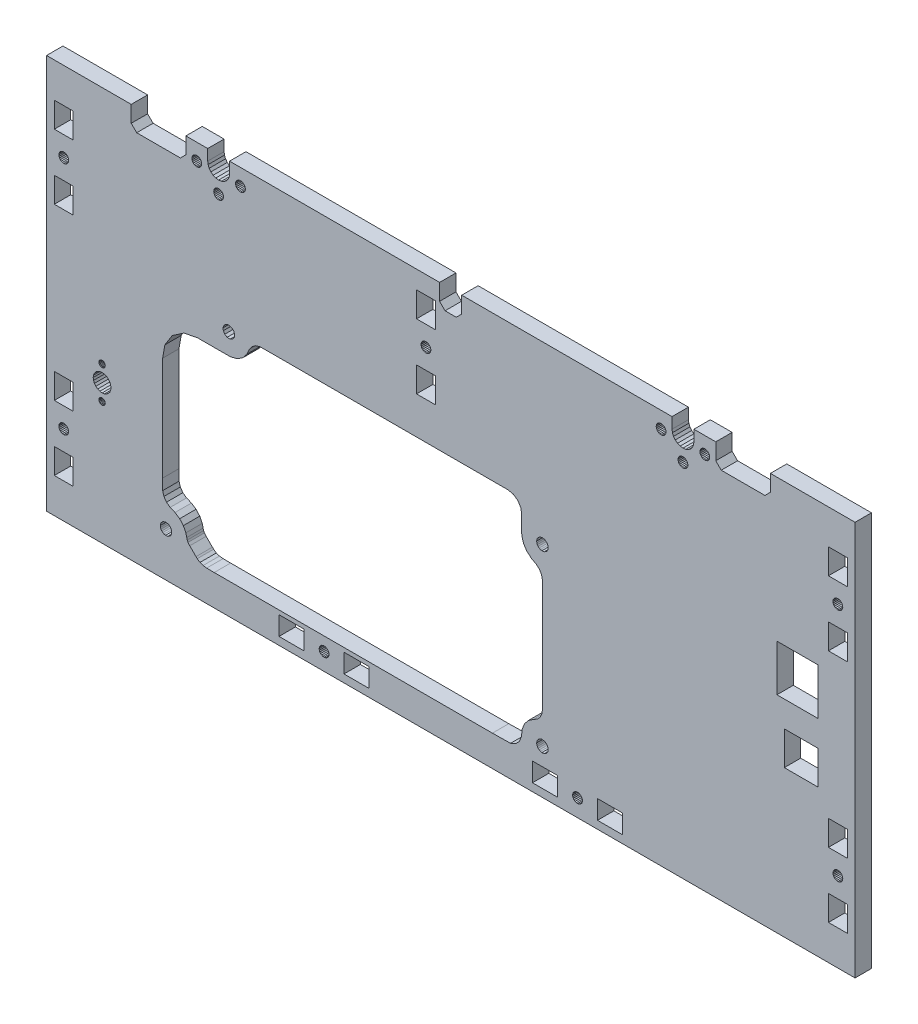
from build123d import *

# Parameters (mm, degrees)
SKETCH1_W           = 9.199995837
SKETCH1_H           = 6.900001918
SKETCH1_W_2         = 9.1999977
SKETCH1_W_3         = 6.900001918
SKETCH1_H_2         = 9.1999977
SKETCH1_H_3         = 9.199995837
SKETCH1_W_4         = 6.900001917
SKETCH1_W_5         = 15
SKETCH1_H_4         = 17
SKETCH1_W_6         = 12.3
SKETCH1_H_5         = 12.3
BOSS_EXTRUDE1_DEPTH = 6


with BuildPart() as part:
    # Sketch1 → Boss-Extrude1 (new body)
    with BuildSketch(Plane.XY):
        Polygon((-23.944821085, -85.732154182), (-22.980097574, -86.131755744), (-21.944821725, -86.268052395), (-20.909545876, -86.131755744), (-19.944822365, -85.732154182), (-19.116395506, -85.096479895), (-18.480721219, -84.268053035), (-18.081119656, -83.303329524), (-17.944823005, -82.268053675), (-17.944823005, -78.268054955), (-9.944825565, -78.268054955), (-9.944825565, -84.268053035), (-7.944826205, -86.268052395), (8.055168675, -86.268052395), (10.055168035, -84.268053035), (10.055168035, -78.268054955), (41.055158115, -78.268054955), (41.055158115, -222.768036235), (-254.944747165, -222.768036235), (-254.944747165, -78.268054955), (-223.944757085, -78.268054955), (-223.944757085, -84.268053035), (-221.944757725, -86.268052395), (-205.944762845, -86.268052395), (-203.944763485, -84.268053035), (-203.944763485, -78.268054955), (-195.944766045, -78.268054955), (-195.944766045, -82.268053675), (-195.808469394, -83.303329524), (-195.408867832, -84.268053035), (-194.773193545, -85.096479895), (-193.944766685, -85.732154182), (-192.980043174, -86.131755744), (-191.944767325, -86.268052395), (-190.909491476, -86.131755744), (-189.944767965, -85.732154182), (-189.116341106, -85.096479895), (-188.480666819, -84.268053035), (-188.081065256, -83.303329524), (-187.944768605, -82.268053675), (-187.944768605, -78.268054955), (-111.044791325, -78.268054955), (-111.044791325, -84.268053035), (-109.044791965, -86.268052395), (-104.944797085, -86.268052395), (-102.944797725, -84.268053035), (-102.944797725, -78.268054955), (-25.944820445, -78.268054955), (-25.944820445, -82.268053675), (-25.808523794, -83.303329524), (-25.408922232, -84.268053035), (-24.773247945, -85.096479895), align=None)
        Polygon((-201.503609993, -85.168052747), (-201.217556564, -85.540844834), (-200.844764477, -85.826898263), (-200.410638897, -86.006718966), (-199.944764765, -86.068052459), (-199.478890633, -86.006718966), (-199.044765053, -85.826898263), (-198.671972966, -85.540844834), (-198.385919537, -85.168052747), (-198.206098834, -84.733927167), (-198.144765341, -84.268053035), (-198.206098834, -83.802178903), (-198.385919537, -83.368053323), (-198.671972966, -82.995261236), (-199.044765053, -82.709207807), (-199.478890633, -82.529387104), (-199.944764765, -82.468053611), (-200.410638897, -82.529387104), (-200.844764477, -82.709207807), (-201.217556564, -82.995261236), (-201.503609993, -83.368053323), (-201.683430696, -83.802178903), (-201.744764189, -84.268053035), (-201.683430696, -84.733927167), align=None, mode=Mode.SUBTRACT)
        Polygon((35.221479877, -105.677712709), (34.755159077, -105.616320411), (34.288838277, -105.677712709), (33.854296469, -105.85770582), (33.481146959, -106.144033509), (33.19481927, -106.517183019), (33.014826159, -106.951724827), (32.953433861, -107.418045627), (33.014826159, -107.884366427), (33.19481927, -108.318908235), (33.481146959, -108.692057745), (33.854296469, -108.978385434), (34.288838277, -109.158378545), (34.755159077, -109.219770843), (35.221479877, -109.158378545), (35.656021685, -108.978385434), (36.029171195, -108.692057745), (36.315498884, -108.318908235), (36.495491995, -107.884366427), (36.556884293, -107.418045627), (36.495491995, -106.951724827), (36.315498884, -106.517183019), (36.029171195, -106.144033509), (35.656021685, -105.85770582), align=None, mode=Mode.SUBTRACT)
        Polygon((-185.504731524, -85.168052747), (-185.218678095, -85.540844834), (-184.845886008, -85.826898263), (-184.411760428, -86.006718966), (-183.945886296, -86.068052459), (-183.480012164, -86.006718966), (-183.045886584, -85.826898263), (-182.673094497, -85.540844834), (-182.387041068, -85.168052747), (-182.207220365, -84.733927167), (-182.145886872, -84.268053035), (-182.207220365, -83.802178903), (-182.387041068, -83.368053323), (-182.673094497, -82.995261236), (-183.045886584, -82.709207807), (-183.480012164, -82.529387104), (-183.945886296, -82.468053611), (-184.411760428, -82.529387104), (-184.845886008, -82.709207807), (-185.218678095, -82.995261236), (-185.504731524, -83.368053323), (-185.684552227, -83.802178903), (-185.74588572, -84.268053035), (-185.684552227, -84.733927167), align=None, mode=Mode.SUBTRACT)
        Polygon((-21.044822013, -92.326896183), (-20.672029926, -92.040842754), (-20.385976497, -91.668050667), (-20.206155794, -91.233925087), (-20.144822301, -90.768050955), (-20.206155794, -90.302176823), (-20.385976497, -89.868051243), (-20.672029926, -89.495259156), (-21.044822013, -89.209205727), (-21.478947593, -89.029385024), (-21.944821725, -88.968051531), (-22.410695857, -89.029385024), (-22.844821437, -89.209205727), (-23.217613524, -89.495259156), (-23.503666953, -89.868051243), (-23.683487656, -90.302176823), (-23.744821149, -90.768050955), (-23.683487656, -91.233925087), (-23.503666953, -91.668050667), (-23.217613524, -92.040842754), (-22.844821437, -92.326896183), (-22.410695857, -92.506716886), (-21.944821725, -92.568050379), (-21.478947593, -92.506716886), align=None, mode=Mode.SUBTRACT)
        Polygon((-15.684606627, -83.802178903), (-15.74594012, -84.268053035), (-15.684606627, -84.733927167), (-15.504785924, -85.168052747), (-15.218732495, -85.540844834), (-14.845940408, -85.826898263), (-14.411814828, -86.006718966), (-13.945940696, -86.068052459), (-13.480066564, -86.006718966), (-13.045940984, -85.826898263), (-12.673148897, -85.540844834), (-12.387095468, -85.168052747), (-12.207274765, -84.733927167), (-12.145941272, -84.268053035), (-12.207274765, -83.802178903), (-12.387095468, -83.368053323), (-12.673148897, -82.995261236), (-13.045940984, -82.709207807), (-13.480066564, -82.529387104), (-13.945940696, -82.468053611), (-14.411814828, -82.529387104), (-14.845940408, -82.709207807), (-15.218732495, -82.995261236), (-15.504785924, -83.368053323), align=None, mode=Mode.SUBTRACT)
        Polygon((-250.205086013, -108.418908203), (-249.918758324, -108.792057713), (-249.545608814, -109.078385402), (-249.111067006, -109.258378513), (-248.644746206, -109.319770811), (-248.178425406, -109.258378513), (-247.743883598, -109.078385402), (-247.370734088, -108.792057713), (-247.084406398, -108.418908203), (-246.904413288, -107.984366395), (-246.84302099, -107.518045595), (-246.904413288, -107.051724795), (-247.084406398, -106.617182987), (-247.370734088, -106.244033477), (-247.743883598, -105.957705788), (-248.178425406, -105.777712677), (-248.644746206, -105.716320379), (-249.111067006, -105.777712677), (-249.545608814, -105.957705788), (-249.918758324, -106.244033477), (-250.205086013, -106.617182987), (-250.385079123, -107.051724795), (-250.446471421, -107.518045595), (-250.385079123, -107.984366395), align=None, mode=Mode.SUBTRACT)
        Polygon((-192.844767037, -92.326896183), (-192.410641457, -92.506716886), (-191.944767325, -92.568050379), (-191.478893193, -92.506716886), (-191.044767613, -92.326896183), (-190.671975526, -92.040842754), (-190.385922097, -91.668050667), (-190.206101394, -91.233925087), (-190.144767901, -90.768050955), (-190.206101394, -90.302176823), (-190.385922097, -89.868051243), (-190.671975526, -89.495259156), (-191.044767613, -89.209205727), (-191.478893193, -89.029385024), (-191.944767325, -88.968051531), (-192.410641457, -89.029385024), (-192.844767037, -89.209205727), (-193.217559124, -89.495259156), (-193.503612553, -89.868051243), (-193.683433256, -90.302176823), (-193.744766749, -90.768050955), (-193.683433256, -91.233925087), (-193.503612553, -91.668050667), (-193.217559124, -92.040842754), align=None, mode=Mode.SUBTRACT)
        Polygon((-60.544813403, -218.269763467), (-60.078492603, -218.208371169), (-59.643950795, -218.028378058), (-59.270801285, -217.742050369), (-58.984473595, -217.368900859), (-58.804480485, -216.934359051), (-58.743088187, -216.468038251), (-58.804480485, -216.001717451), (-58.984473595, -215.567175643), (-59.270801285, -215.194026133), (-59.643950795, -214.907698444), (-60.078492603, -214.727705333), (-60.544813403, -214.666313035), (-61.011134202, -214.727705333), (-61.44567601, -214.907698444), (-61.81882552, -215.194026133), (-62.10515321, -215.567175643), (-62.28514632, -216.001717451), (-62.346538618, -216.468038251), (-62.28514632, -216.934359051), (-62.10515321, -217.368900859), (-61.81882552, -217.742050369), (-61.44567601, -218.028378058), (-61.011134202, -218.208371169), align=None, mode=Mode.SUBTRACT)
        Polygon((-153.811096448, -214.727705333), (-154.245638256, -214.907698444), (-154.618787766, -215.194026133), (-154.905115455, -215.567175643), (-155.085108566, -216.001717451), (-155.146500864, -216.468038251), (-155.085108566, -216.934359051), (-154.905115455, -217.368900859), (-154.618787766, -217.742050369), (-154.245638256, -218.028378058), (-153.811096448, -218.208371169), (-153.344775648, -218.269763467), (-152.878454848, -218.208371169), (-152.44391304, -218.028378058), (-152.07076353, -217.742050369), (-151.784435841, -217.368900859), (-151.60444273, -216.934359051), (-151.543050432, -216.468038251), (-151.60444273, -216.001717451), (-151.784435841, -215.567175643), (-152.07076353, -215.194026133), (-152.44391304, -214.907698444), (-152.878454848, -214.727705333), (-153.344775648, -214.666313035), align=None, mode=Mode.SUBTRACT)
        Polygon((-29.044819453, -82.709207807), (-29.478945033, -82.529387104), (-29.944819165, -82.468053611), (-30.410693297, -82.529387104), (-30.844818877, -82.709207807), (-31.217610964, -82.995261236), (-31.503664393, -83.368053323), (-31.683485096, -83.802178903), (-31.744818589, -84.268053035), (-31.683485096, -84.733927167), (-31.503664393, -85.168052747), (-31.217610964, -85.540844834), (-30.844818877, -85.826898263), (-30.410693297, -86.006718966), (-29.944819165, -86.068052459), (-29.478945033, -86.006718966), (-29.044819453, -85.826898263), (-28.672027366, -85.540844834), (-28.385973937, -85.168052747), (-28.206153234, -84.733927167), (-28.144819741, -84.268053035), (-28.206153234, -83.802178903), (-28.385973937, -83.368053323), (-28.672027366, -82.995261236), align=None, mode=Mode.SUBTRACT)
        with Locations((-48.644817352, -216.46803729)):
            Rectangle(SKETCH1_W, SKETCH1_H, mode=Mode.SUBTRACT)
        with Locations((-72.444808182, -216.46803729)):
            Rectangle(SKETCH1_W_2, SKETCH1_H, mode=Mode.SUBTRACT)
        with Locations((-165.244770427, -216.46803729)):
            Rectangle(SKETCH1_W_2, SKETCH1_H, mode=Mode.SUBTRACT)
        with Locations((-141.444779598, -216.46803729)):
            Rectangle(SKETCH1_W, SKETCH1_H, mode=Mode.SUBTRACT)
        with Locations((34.755158116, -119.318040406)):
            Rectangle(SKETCH1_W_3, SKETCH1_H_2, mode=Mode.SUBTRACT)
        with Locations((34.755158116, -95.518049577)):
            Rectangle(SKETCH1_W_3, SKETCH1_H_3, mode=Mode.SUBTRACT)
        with Locations((-248.644747167, -119.418040374)):
            Rectangle(SKETCH1_W_4, SKETCH1_H_2, mode=Mode.SUBTRACT)
        with Locations((-248.644747167, -95.618049544)):
            Rectangle(SKETCH1_W_4, SKETCH1_H_3, mode=Mode.SUBTRACT)
        with Locations((-248.644747167, -205.418037385)):
            Rectangle(SKETCH1_W_4, SKETCH1_H_2, mode=Mode.SUBTRACT)
        with Locations((-248.644747167, -181.618046556)):
            Rectangle(SKETCH1_W_4, SKETCH1_H_3, mode=Mode.SUBTRACT)
        Polygon((-246.904413288, -193.984363406), (-246.84302099, -193.518042606), (-246.904413288, -193.051721806), (-247.084406398, -192.617179998), (-247.370734088, -192.244030488), (-247.743883598, -191.957702798), (-248.178425406, -191.777709688), (-248.644746206, -191.71631739), (-249.111067006, -191.777709688), (-249.545608814, -191.957702798), (-249.918758324, -192.244030488), (-250.205086013, -192.617179998), (-250.385079123, -193.051721806), (-250.446471421, -193.518042606), (-250.385079123, -193.984363406), (-250.205086013, -194.418905214), (-249.918758324, -194.792054724), (-249.545608814, -195.078382413), (-249.111067006, -195.258375523), (-248.644746206, -195.319767821), (-248.178425406, -195.258375523), (-247.743883598, -195.078382413), (-247.370734088, -194.792054724), (-247.084406398, -194.418905214), align=None, mode=Mode.SUBTRACT)
        with Locations((34.755158116, -205.418037385)):
            Rectangle(SKETCH1_W_3, SKETCH1_H_2, mode=Mode.SUBTRACT)
        Polygon((36.495491995, -193.984363406), (36.556884293, -193.518042606), (36.495491995, -193.051721806), (36.315498884, -192.617179998), (36.029171195, -192.244030488), (35.656021685, -191.957702798), (35.221479877, -191.777709688), (34.755159077, -191.71631739), (34.288838277, -191.777709688), (33.854296469, -191.957702798), (33.481146959, -192.244030488), (33.19481927, -192.617179998), (33.014826159, -193.051721806), (32.953433861, -193.518042606), (33.014826159, -193.984363406), (33.19481927, -194.418905214), (33.481146959, -194.792054724), (33.854296469, -195.078382413), (34.288838277, -195.258375523), (34.755159077, -195.319767821), (35.221479877, -195.258375523), (35.656021685, -195.078382413), (36.029171195, -194.792054724), (36.315498884, -194.418905214), align=None, mode=Mode.SUBTRACT)
        with Locations((34.755158116, -181.618046556)):
            Rectangle(SKETCH1_W_3, SKETCH1_H_3, mode=Mode.SUBTRACT)
        Polygon((-232.993947452, -174.669693627), (-232.320850413, -174.153208103), (-231.80436489, -173.480111064), (-231.479688517, -172.696272961), (-231.368947452, -171.855111064), (-231.479688517, -171.013949168), (-231.80436489, -170.230111064), (-232.320850413, -169.557014025), (-232.993947452, -169.040528502), (-233.777785556, -168.715852129), (-234.618947452, -168.605111064), (-235.460109349, -168.715852129), (-236.243947452, -169.040528502), (-236.917044491, -169.557014025), (-237.433530015, -170.230111064), (-237.758206388, -171.013949168), (-237.868947452, -171.855111064), (-237.758206388, -172.696272961), (-237.433530015, -173.480111064), (-236.917044491, -174.153208103), (-236.243947452, -174.669693627), (-235.460109349, -174.99437), (-234.618947452, -175.105111064), (-233.777785556, -174.99437), align=None, mode=Mode.SUBTRACT)
        Polygon((-235.753910298, -166.190223442), (-235.636527302, -166.473611064), (-235.44979792, -166.716961532), (-235.206447452, -166.903690914), (-234.92305983, -167.02107391), (-234.618947452, -167.061111064), (-234.314835074, -167.02107391), (-234.031447452, -166.903690914), (-233.788096984, -166.716961532), (-233.601367603, -166.473611064), (-233.483984606, -166.190223442), (-233.443947452, -165.886111064), (-233.483984606, -165.581998686), (-233.601367603, -165.298611064), (-233.788096984, -165.055260596), (-234.031447452, -164.868531215), (-234.314835074, -164.751148218), (-234.618947452, -164.711111064), (-234.92305983, -164.751148218), (-235.206447452, -164.868531215), (-235.44979792, -165.055260596), (-235.636527302, -165.298611064), (-235.753910298, -165.581998686), (-235.793947452, -165.886111064), align=None, mode=Mode.SUBTRACT)
        Polygon((-234.314835074, -178.95907391), (-234.031447452, -178.841690914), (-233.788096984, -178.654961532), (-233.601367603, -178.411611064), (-233.483984606, -178.128223442), (-233.443947452, -177.824111064), (-233.483984606, -177.519998686), (-233.601367603, -177.236611064), (-233.788096984, -176.993260596), (-234.031447452, -176.806531215), (-234.314835074, -176.689148218), (-234.618947452, -176.649111064), (-234.92305983, -176.689148218), (-235.206447452, -176.806531215), (-235.44979792, -176.993260596), (-235.636527302, -177.236611064), (-235.753910298, -177.519998686), (-235.793947452, -177.824111064), (-235.753910298, -178.128223442), (-235.636527302, -178.411611064), (-235.44979792, -178.654961532), (-235.206447452, -178.841690914), (-234.92305983, -178.95907391), (-234.618947452, -178.999111064), align=None, mode=Mode.SUBTRACT)
        Polygon((-114.304458664, -100.880798627), (-114.484451774, -100.446256819), (-114.770779463, -100.073107309), (-115.143928973, -99.78677962), (-115.578470781, -99.60678651), (-116.044791581, -99.545394212), (-116.511112381, -99.60678651), (-116.945654189, -99.78677962), (-117.318803699, -100.073107309), (-117.605131389, -100.446256819), (-117.785124499, -100.880798627), (-117.846516797, -101.347119427), (-117.785124499, -101.813440227), (-117.605131389, -102.247982035), (-117.318803699, -102.621131545), (-116.945654189, -102.907459234), (-116.511112381, -103.087452345), (-116.044791581, -103.148844643), (-115.578470781, -103.087452345), (-115.143928973, -102.907459234), (-114.770779463, -102.621131545), (-114.484451774, -102.247982035), (-114.304458664, -101.813440227), (-114.243066366, -101.347119427), align=None, mode=Mode.SUBTRACT)
        with Locations((-116.044790621, -89.447124648)):
            Rectangle(SKETCH1_W_4, SKETCH1_H_2, mode=Mode.SUBTRACT)
        with Locations((-116.044790621, -113.247115478)):
            Rectangle(SKETCH1_W_4, SKETCH1_H_3, mode=Mode.SUBTRACT)
        with Locations((19.955158115, -138.768036235)):
            Rectangle(SKETCH1_W_5, SKETCH1_H_4, mode=Mode.SUBTRACT)
        Polygon((-213.059274162, -205.505337406), (-212.378856681, -204.7561543), (-211.408019279, -204.404207523), (-210.363607462, -204.560230081), (-209.550999552, -205.166541117), (-209.108923869, -206.089976175), (-209.161287443, -207.150144437), (-209.688151212, -208.020836331), (-210.558843107, -208.547700101), (-211.408019279, -208.63226514), (-211.921395438, -208.514291324), (-212.378856681, -208.280318363), (-212.763712943, -207.947036319), (-213.059274162, -207.531135257), (-213.248850272, -207.04930524), (-213.315751212, -206.518236331), align=None, mode=Mode.SUBTRACT)
        Polygon((-77.306283883, -149.047825916), (-75.631933075, -149.935403456), (-74.499097357, -150.958970732), (-73.741565214, -152.260517878), (-73.404342936, -153.771130033), (-73.390951212, -158.389748331), (-73.390951212, -194.863104175), (-73.600359025, -196.362270706), (-74.242395113, -197.730582841), (-75.272593717, -198.840605066), (-76.728076241, -199.672524235), (-78.596132012, -200.965571131), (-80.003998771, -202.744043265), (-80.834944506, -204.891208625), (-81.065994466, -207.188096851), (-81.783958437, -209.128372106), (-83.182775418, -210.600301227), (-85.072804728, -211.415415628), (-91.718012042, -211.518036331), (-193.570932125, -211.518036331), (-196.318962931, -211.487673197), (-197.619425862, -211.310836306), (-198.7809986, -210.917602094), (-199.7729462, -210.242007641), (-200.223756079, -209.796496035), (-202.516165269, -207.517563696), (-203.156302707, -206.780286127), (-203.452991412, -206.179587119), (-203.62411088, -205.451018094), (-203.955512262, -204.133038096), (-204.859251987, -202.291492761), (-206.204476812, -200.767947531), (-207.907143162, -199.646478539), (-209.683052775, -198.937347269), (-211.037219072, -197.955318625), (-211.977658462, -196.606025181), (-212.433177009, -194.986533794), (-212.464951212, -191.031588919), (-212.464951212, -153.026733296), (-211.648782176, -148.380460233), (-208.908938472, -144.05692745), (-204.70029965, -141.156553519), (-199.75957483, -140.155836331), (-189.401815212, -140.155836331), (-187.578297843, -140.130612601), (-185.140296059, -139.511284063), (-183.084391146, -138.172131896), (-181.557377187, -136.259928481), (-180.695282995, -134.287578469), (-179.728065861, -132.953324417), (-178.406548293, -132.021649963), (-176.821904112, -131.557942831), (-174.480732957, -131.518036331), (-86.090951212, -131.518036331), (-84.026136302, -131.957825304), (-82.366314431, -133.149419363), (-81.303144888, -134.901159218), (-81.010951212, -136.640956331), (-81.010951212, -142.099866956), (-80.955313712, -143.437995431), (-80.317524538, -145.68485129), (-79.06165922, -147.594295121), align=None, mode=Mode.SUBTRACT)
        Polygon((-188.830659318, -134.565500101), (-189.701351212, -134.038636331), (-190.228214982, -133.167944437), (-190.312780021, -132.318768265), (-190.194806205, -131.805392105), (-189.960833244, -131.347930863), (-189.6275512, -130.9630746), (-189.211650138, -130.667513382), (-188.729820121, -130.477937271), (-188.198751212, -130.411036331), (-187.185852287, -130.667513382), (-186.436669181, -131.347930863), (-186.084722404, -132.318768265), (-186.240744962, -133.363180081), (-186.847055998, -134.175787992), (-187.770491056, -134.617863675), align=None, mode=Mode.SUBTRACT)
        Polygon((-74.578856681, -208.280318363), (-74.963712943, -207.947036319), (-75.259274162, -207.531135257), (-75.448850272, -207.04930524), (-75.515751212, -206.518236331), (-75.259274162, -205.505337406), (-74.578856681, -204.7561543), (-73.608019279, -204.404207523), (-72.563607462, -204.560230081), (-71.750999552, -205.166541117), (-71.308923869, -206.089976175), (-71.361287443, -207.150144437), (-71.888151212, -208.020836331), (-72.758843107, -208.547700101), (-73.608019279, -208.63226514), (-74.121395438, -208.514291324), align=None, mode=Mode.SUBTRACT)
        Polygon((-74.578856681, -144.280318363), (-74.963712943, -143.947036319), (-75.259274162, -143.531135257), (-75.448850272, -143.04930524), (-75.515751212, -142.518236331), (-75.259274162, -141.505337406), (-74.578856681, -140.7561543), (-73.608019279, -140.404207523), (-72.563607462, -140.560230081), (-71.750999552, -141.166541117), (-71.308923869, -142.089976175), (-71.361287443, -143.150144437), (-71.888151212, -144.020836331), (-72.758843107, -144.547700101), (-73.608019279, -144.63226514), (-74.121395438, -144.514291324), align=None, mode=Mode.SUBTRACT)
        with Locations((21.305158115, -162.866890841)):
            Rectangle(SKETCH1_W_6, SKETCH1_H_5, mode=Mode.SUBTRACT)
    extrude(amount=BOSS_EXTRUDE1_DEPTH)


solid = part.part
